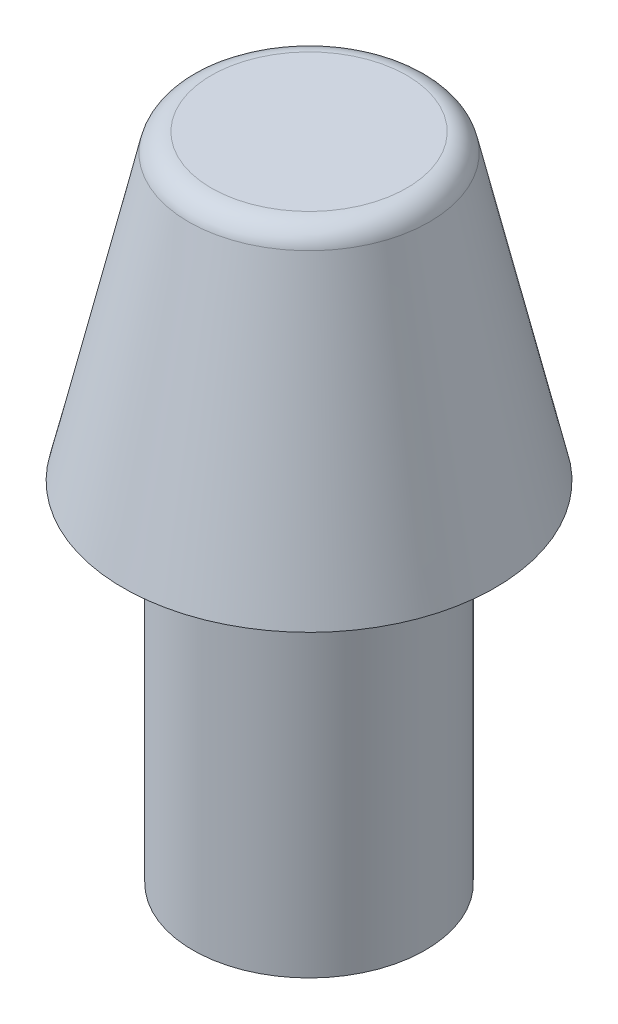
from build123d import *


with BuildPart() as part:
    # Sketch1 → Revolve1 (revolve)
    with BuildSketch(Plane.XY):
        with BuildLine():
            Line((0, 0), (0, 7))
            Line((0, 7), (1.051121845, 7))
            ThreePointArc((1.051121845, 7), (1.206759695, 6.945644728), (1.294719644, 6.806214877))
            Line((1.294719644, 6.806214877), (2, 3.75))
            Line((2, 3.75), (1.25, 3.75))
            Line((1.25, 3.75), (1.25, 0))
            Line((1.25, 0), (0, 0))
        make_face()
    revolve(axis=Axis((0, 0, 0), (0, 1, 0)))


solid = part.part
